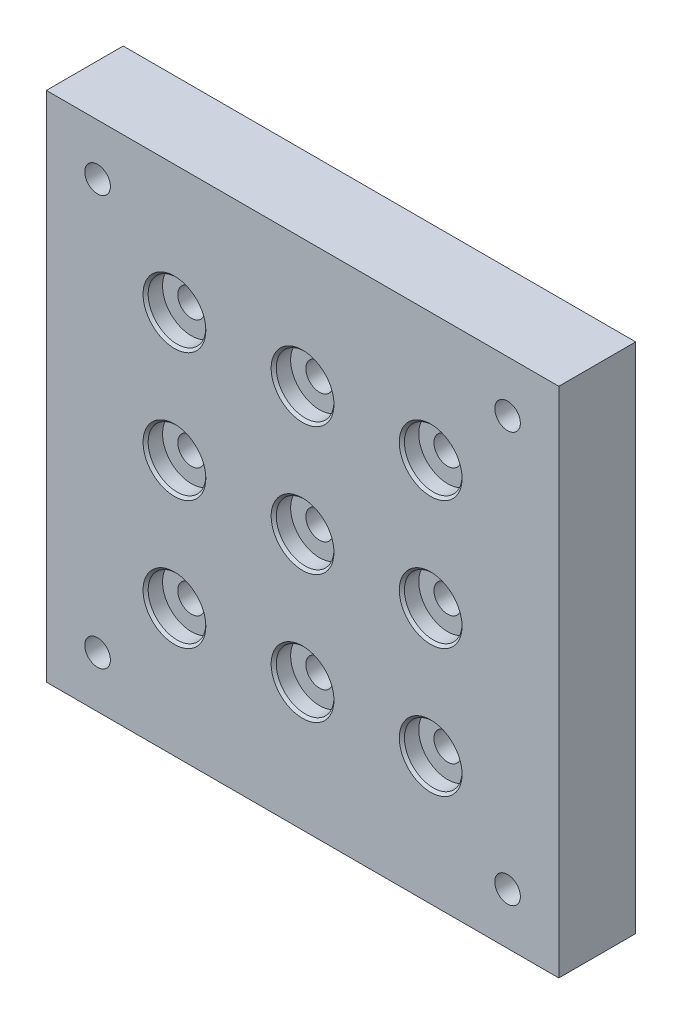
from build123d import *

# Parameters (mm, degrees)
SKETCH2_W                       = 127
SKETCH2_H                       = 127
BOSS_EXTRUDE1_DEPTH             = 19.05
LPATTERN1_COUNT                 = 2
LPATTERN1_PITCH                 = 31.75
LPATTERN1_COL_COUNT             = 2
LPATTERN1_COL_PITCH             = 31.75
LPATTERN2_COUNT                 = 2
LPATTERN2_PITCH                 = 31.75
LPATTERN2_COL_COUNT             = 2
LPATTERN2_COL_PITCH             = 31.75
F_1_4_0_25_DIAMETER_HOLE1_D     = 6.35
F_1_4_0_25_DIAMETER_HOLE1_DEPTH = 59.944
F_1_4_0_25_DIAMETER_HOLE1_TIP   = 1.907732465


with BuildPart() as part:
    # Sketch2 → Boss-Extrude1 (new body)
    with BuildSketch(Plane.XY):
        Rectangle(SKETCH2_W, SKETCH2_H)
    extrude(amount=BOSS_EXTRUDE1_DEPTH)

    # Sketch5 → CBORE for 1/4 Binding Head Machine Screw1 (revolve, cut)
    with BuildSketch(Plane(origin=(0, 0, 19.05), x_dir=(0, -1, 0), z_dir=(1, 0, 0))):
        Polygon((0, 0), (0, 19.05), (3.3782, 19.05), (3.3782, 4.191), (7.14375, 4.191), (7.14375, 0.635), (7.77875, 0), align=None)
    cbore_for_1_4_binding_head_machine_screw = revolve(axis=Axis((0, 0, 25.4), (0, 0, -1)), mode=Mode.SUBTRACT)

    # LPattern1: CBORE for 1/4 Binding Head Machine Screw1 ×2
    with Locations(*[(i * LPATTERN1_PITCH, 0, 0) for i in range(1, LPATTERN1_COUNT)]):
        add(cbore_for_1_4_binding_head_machine_screw, mode=Mode.SUBTRACT)

    # LPattern1 col: CBORE for 1/4 Binding Head Machine Screw1 ×2
    with Locations(*[(-i * LPATTERN1_COL_PITCH, 0, 0) for i in range(1, LPATTERN1_COL_COUNT)]):
        add(cbore_for_1_4_binding_head_machine_screw, mode=Mode.SUBTRACT)

    # LPattern2: CBORE for 1/4 Binding Head Machine Screw1 ×2
    with Locations(*[(0, -i * LPATTERN2_PITCH, 0) for i in range(1, LPATTERN2_COUNT)]):
        add(cbore_for_1_4_binding_head_machine_screw, mode=Mode.SUBTRACT)

    # LPattern2 copy 1 sketch → LPattern2 copy 1 (revolve, cut)
    with BuildSketch(Plane(origin=(31.75, -31.75, 19.05), x_dir=(0, -1, 0), z_dir=(1, 0, 0))):
        Polygon((0, 0), (0, 19.05), (3.3782, 19.05), (3.3782, 4.191), (7.14375, 4.191), (7.14375, 0.635), (7.77875, 0), align=None)
    revolve(axis=Axis((31.75, -31.75, 25.4), (0, 0, -1)), mode=Mode.SUBTRACT)

    # LPattern2 copy 2 sketch → LPattern2 copy 2 (revolve, cut)
    with BuildSketch(Plane(origin=(-31.75, -31.75, 19.05), x_dir=(0, -1, 0), z_dir=(1, 0, 0))):
        Polygon((0, 0), (0, 19.05), (3.3782, 19.05), (3.3782, 4.191), (7.14375, 4.191), (7.14375, 0.635), (7.77875, 0), align=None)
    revolve(axis=Axis((-31.75, -31.75, 25.4), (0, 0, -1)), mode=Mode.SUBTRACT)

    # LPattern2 col: CBORE for 1/4 Binding Head Machine Screw1 ×2
    with Locations(*[(0, i * LPATTERN2_COL_PITCH, 0) for i in range(1, LPATTERN2_COL_COUNT)]):
        add(cbore_for_1_4_binding_head_machine_screw, mode=Mode.SUBTRACT)

    # LPattern2 col copy 1 sketch → LPattern2 col copy 1 (revolve, cut)
    with BuildSketch(Plane(origin=(31.75, 31.75, 19.05), x_dir=(0, -1, 0), z_dir=(1, 0, 0))):
        Polygon((0, 0), (0, 19.05), (3.3782, 19.05), (3.3782, 4.191), (7.14375, 4.191), (7.14375, 0.635), (7.77875, 0), align=None)
    revolve(axis=Axis((31.75, 31.75, 25.4), (0, 0, -1)), mode=Mode.SUBTRACT)

    # LPattern2 col copy 2 sketch → LPattern2 col copy 2 (revolve, cut)
    with BuildSketch(Plane(origin=(-31.75, 31.75, 19.05), x_dir=(0, -1, 0), z_dir=(1, 0, 0))):
        Polygon((0, 0), (0, 19.05), (3.3782, 19.05), (3.3782, 4.191), (7.14375, 4.191), (7.14375, 0.635), (7.77875, 0), align=None)
    revolve(axis=Axis((-31.75, 31.75, 25.4), (0, 0, -1)), mode=Mode.SUBTRACT)

    # 1/4 (0.25) Diameter Hole1
    with Locations(Plane.XY.offset(19.05)):
        with Locations((-50.8, 50.8), (50.8, 50.8), (50.8, -50.8), (-50.8, -50.8)):
            Hole(F_1_4_0_25_DIAMETER_HOLE1_D / 2, depth=F_1_4_0_25_DIAMETER_HOLE1_DEPTH)
            with Locations((0, 0, -(F_1_4_0_25_DIAMETER_HOLE1_DEPTH + F_1_4_0_25_DIAMETER_HOLE1_TIP / 2))):  # 118° drill point
                Cone(0, F_1_4_0_25_DIAMETER_HOLE1_D / 2, F_1_4_0_25_DIAMETER_HOLE1_TIP, mode=Mode.SUBTRACT)


solid = part.part
